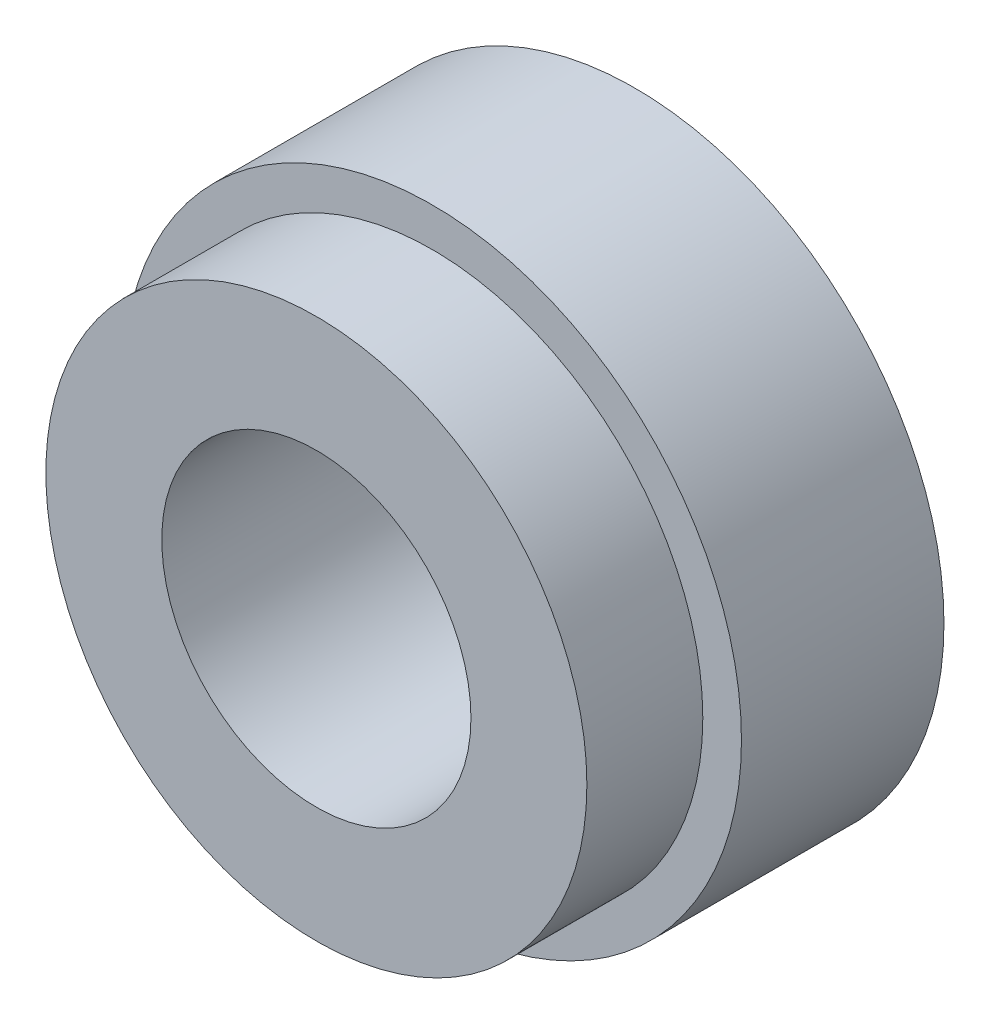
from build123d import *

# Parameters (mm, degrees)
SKETCH1_R           = 50.8
BOSS_EXTRUDE1_DEPTH = 33.274
SKETCH3_R           = 44.45
BOSS_EXTRUDE2_DEPTH = 19.05
SKETCH5_R           = 25.4
CUT_EXTRUDE1_DEPTH  = 53.324


with BuildPart() as part:
    # Sketch1 → Boss-Extrude1 (new body)
    with BuildSketch(Plane.XY):
        Circle(SKETCH1_R)
    extrude(amount=BOSS_EXTRUDE1_DEPTH)

    # Sketch3 → Boss-Extrude2 (add)
    with BuildSketch(Plane.XY.offset(33.274)):
        Circle(SKETCH3_R)
    extrude(amount=BOSS_EXTRUDE2_DEPTH)

    # Sketch5 → Cut-Extrude1 (cut, through all)
    with BuildSketch(Plane.XY):
        Circle(SKETCH5_R)
    extrude(amount=CUT_EXTRUDE1_DEPTH, mode=Mode.SUBTRACT)


solid = part.part
